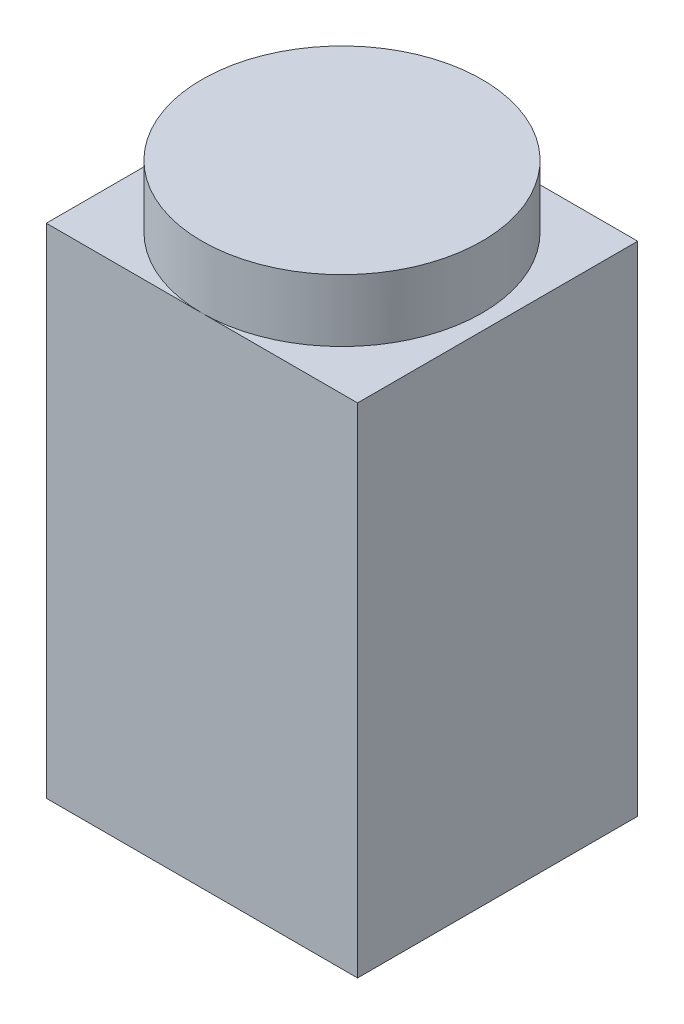
from build123d import *

# Parameters (mm, degrees)
SKETCH1_W           = 50
SKETCH1_H           = 45
BOSS_EXTRUDE1_DEPTH = 45
SKETCH2_OUTSIDE_W   = 74.472
SKETCH2_OUTSIDE_H   = 69.472
SKETCH2_OUTSIDE_R   = 22.5
CUT_EXTRUDE1_DEPTH  = 10


with BuildPart() as part:
    # Sketch1 → Boss-Extrude1 (new body, symmetric)
    with BuildSketch(Plane(origin=(0, 0, 0), x_dir=(1, 0, 0), z_dir=(0, 1, 0))):
        Rectangle(SKETCH1_W, SKETCH1_H)
    extrude(amount=BOSS_EXTRUDE1_DEPTH, both=True)

    # Sketch2 outside → Cut-Extrude1 (cut, symmetric)
    with BuildSketch(Plane(origin=(0, 45, 0), x_dir=(1, 0, 0), z_dir=(0, 1, 0))):
        Rectangle(SKETCH2_OUTSIDE_W, SKETCH2_OUTSIDE_H)
        Circle(SKETCH2_OUTSIDE_R, mode=Mode.SUBTRACT)
    extrude(amount=CUT_EXTRUDE1_DEPTH, both=True, mode=Mode.SUBTRACT)


solid = part.part
